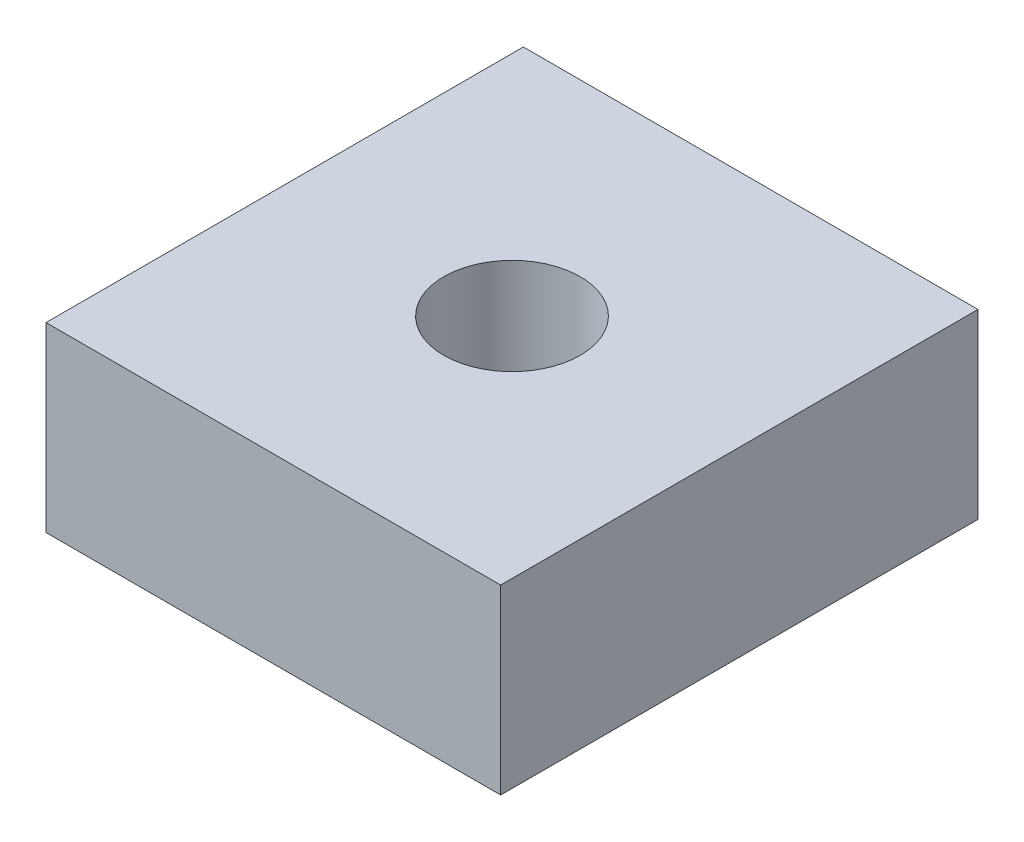
from build123d import *

# Parameters (mm, degrees)
SKETCH1_W           = 10
SKETCH1_H           = 10.5
BOSS_EXTRUDE1_DEPTH = 4
SKETCH2_R           = 1.5
CUT_EXTRUDE1_DEPTH  = 4


with BuildPart() as part:
    # Sketch1 → Boss-Extrude1 (new body)
    with BuildSketch(Plane(origin=(0, 0, 0), x_dir=(1, 0, 0), z_dir=(0, 1, 0))):
        with Locations((5, 5.25)):
            Rectangle(SKETCH1_W, SKETCH1_H)
    extrude(amount=BOSS_EXTRUDE1_DEPTH)

    # Sketch2 → Cut-Extrude1 (cut)
    with BuildSketch(Plane(origin=(0, 4, 0), x_dir=(1, 0, 0), z_dir=(0, 1, 0))):
        with Locations((5, 5.25)):
            Circle(SKETCH2_R)
    extrude(amount=-CUT_EXTRUDE1_DEPTH, mode=Mode.SUBTRACT)


solid = part.part
